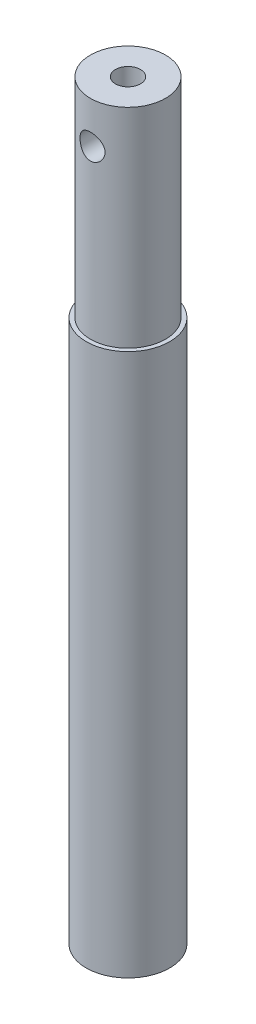
from build123d import *

# Parameters (mm, degrees)
SKETCH1_R           = 5
SKETCH1_R_2         = 2.5
BOSS_EXTRUDE1_DEPTH = 65
SKETCH2_R           = 4.5
SKETCH2_R_2         = 1.5
BOSS_EXTRUDE2_DEPTH = 25
SKETCH4_R           = 1.5
CUT_EXTRUDE1_DEPTH  = 32.5


with BuildPart() as part:
    # Sketch1 → Boss-Extrude1 (new body)
    with BuildSketch(Plane(origin=(0, 0, 0), x_dir=(1, 0, 0), z_dir=(0, 1, 0))):
        Circle(SKETCH1_R)
        Circle(SKETCH1_R_2, mode=Mode.SUBTRACT)
    extrude(amount=BOSS_EXTRUDE1_DEPTH)

    # Sketch2 → Boss-Extrude2 (add)
    with BuildSketch(Plane(origin=(0, 65, 0), x_dir=(1, 0, 0), z_dir=(0, 1, 0))):
        Circle(SKETCH2_R)
        Circle(SKETCH2_R_2, mode=Mode.SUBTRACT)
    extrude(amount=BOSS_EXTRUDE2_DEPTH)

    # Sketch4 → Cut-Extrude1 (cut, symmetric)
    with BuildSketch(Plane.XY):
        with Locations((0, 85)):
            Circle(SKETCH4_R)
    extrude(amount=CUT_EXTRUDE1_DEPTH, both=True, mode=Mode.SUBTRACT)


solid = part.part
